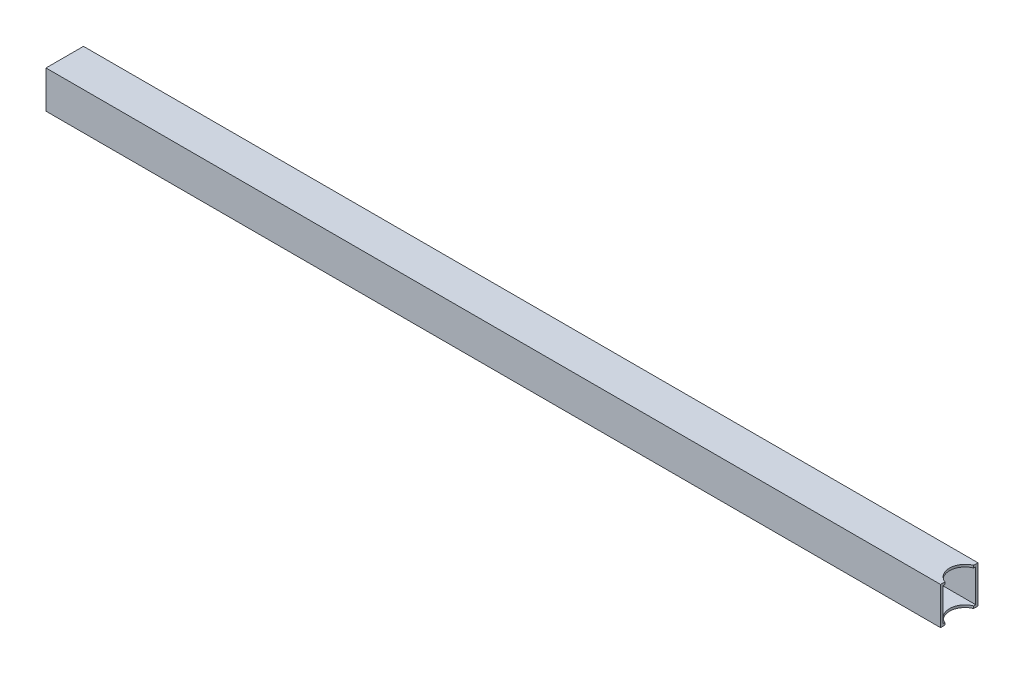
from build123d import *

# Parameters (mm, degrees)
SKETCH1_W                = 50.8
SKETCH1_H                = 50.8
SKETCH1_W_2              = 44.45
SKETCH1_H_2              = 44.45
BOSS_EXTRUDE1_DEPTH      = 590.55
BOSS_EXTRUDE1_DEPTH_BACK = 590.55
SKETCH6_W                = 50.8
SKETCH6_H                = 50.8
SKETCH6_W_2              = 44.45
SKETCH6_H_2              = 44.45
BOSS_EXTRUDE2_DEPTH      = 31.75
SKETCH7_R                = 21.082
CUT_EXTRUDE1_DEPTH       = 50.8


with BuildPart() as part:
    # Sketch1 → Boss-Extrude1 (new body, two sides)
    with BuildSketch(Plane(origin=(0, 0, 0), x_dir=(0, 0, -1), z_dir=(1, 0, 0))) as boss_extrude1_sk:
        Rectangle(SKETCH1_W, SKETCH1_H)
        Rectangle(SKETCH1_W_2, SKETCH1_H_2, mode=Mode.SUBTRACT)
    extrude(amount=BOSS_EXTRUDE1_DEPTH)
    extrude(boss_extrude1_sk.sketch, amount=-BOSS_EXTRUDE1_DEPTH_BACK)

    # Sketch6 → Boss-Extrude2 (add)
    with BuildSketch(Plane(origin=(590.55, 0, 0), x_dir=(0, 0, -1), z_dir=(1, 0, 0))):
        Rectangle(SKETCH6_W, SKETCH6_H)
        Rectangle(SKETCH6_W_2, SKETCH6_H_2, mode=Mode.SUBTRACT)
    extrude(amount=BOSS_EXTRUDE2_DEPTH)

    # Sketch7 → Cut-Extrude1 (cut)
    with BuildSketch(Plane(origin=(0, 25.4, 0), x_dir=(1, 0, 0), z_dir=(0, 1, 0))):
        with Locations((630.2375, 0)):
            Circle(SKETCH7_R)
    extrude(amount=-CUT_EXTRUDE1_DEPTH, mode=Mode.SUBTRACT)


solid = part.part
